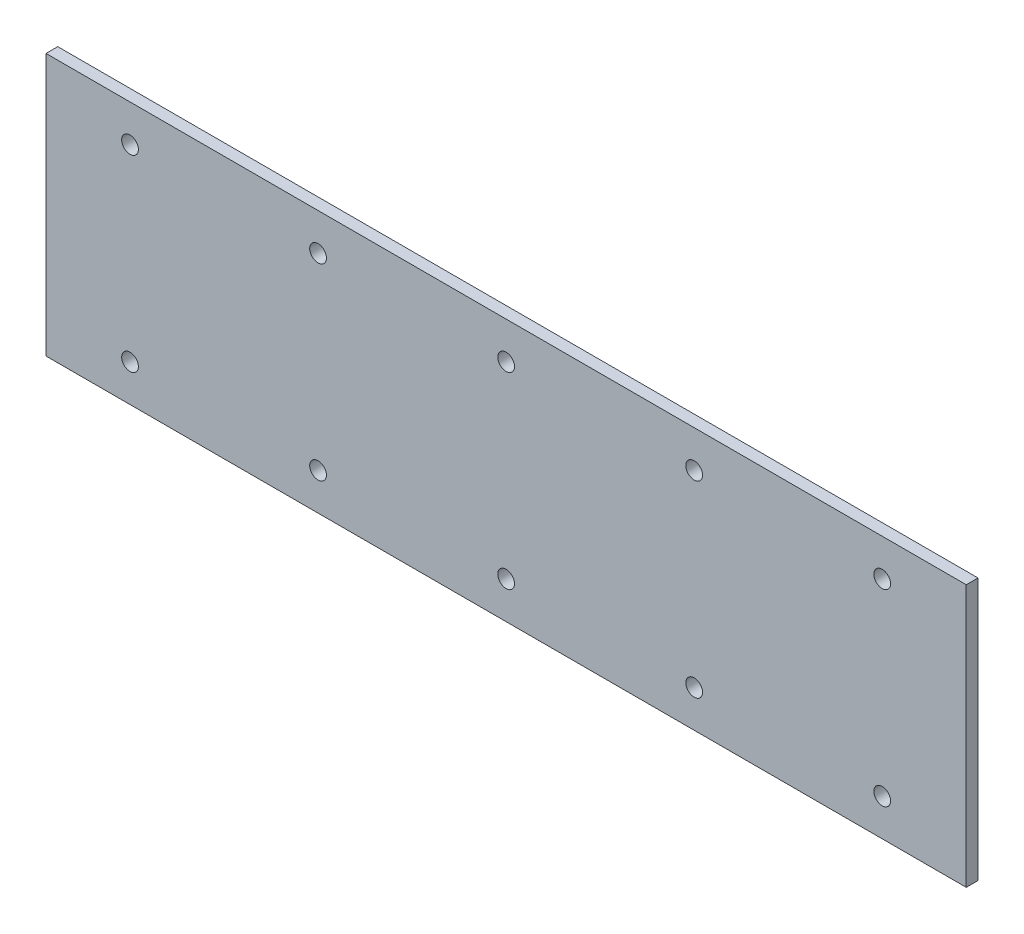
from build123d import *

# Parameters (mm, degrees)
SKETCH1_W             = 124.3
SKETCH1_H             = 35.4
BOSS_EXTRUDE1_DEPTH   = 1.5875
F_4_40_TAPPED_HOLE1_D = 2.2606
LPATTERN1_COUNT       = 5
LPATTERN1_PITCH       = 25.4


with BuildPart() as part:
    # Sketch1 → Boss-Extrude1 (new body)
    with BuildSketch(Plane.XY):
        Rectangle(SKETCH1_W, SKETCH1_H)
    extrude(amount=BOSS_EXTRUDE1_DEPTH)

    # #4-40 Tapped Hole1 (through all)
    with Locations(Plane(origin=(-50.8, 12.7, 1.5875), x_dir=(1, 0, 0), z_dir=(0, 0, 1))):
        with Locations((0, 0), (0, -25.4)):
            f_4_40_tapped_hole1 = Hole(F_4_40_TAPPED_HOLE1_D / 2)

    # LPattern1: #4-40 Tapped Hole1 ×5
    with Locations(*[(i * LPATTERN1_PITCH, 0, 0) for i in range(1, LPATTERN1_COUNT)]):
        add(f_4_40_tapped_hole1, mode=Mode.SUBTRACT)


solid = part.part
